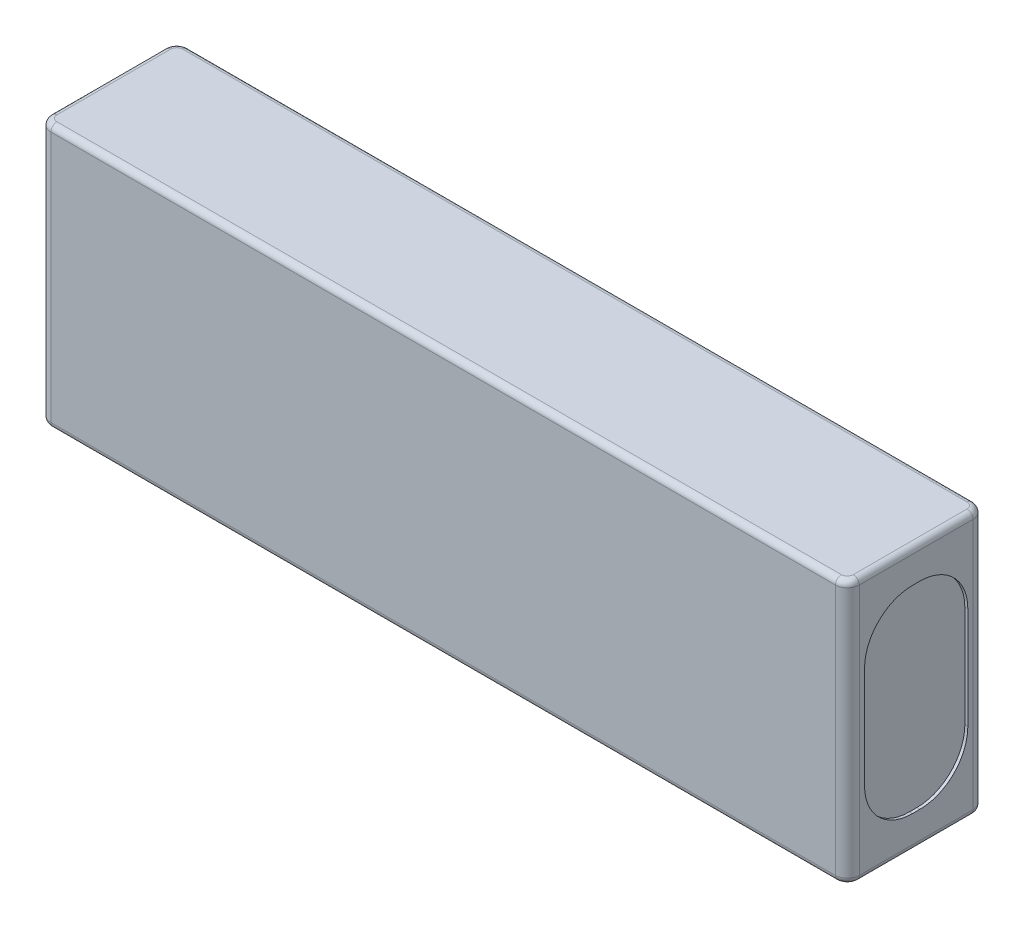
from build123d import *

# Parameters (mm, degrees)
SKETCH1_W           = 135
SKETCH1_H           = 44
BOSS_EXTRUDE1_DEPTH = 23
CUT_EXTRUDE1_DEPTH  = 0.5
CUT_EXTRUDE2_DEPTH  = 0.5
FILLET1_R           = 2
FILLET2_R           = 1


with BuildPart() as part:
    # Sketch1 → Boss-Extrude1 (new body)
    with BuildSketch(Plane(origin=(0, 0, -15), x_dir=(-1, 0, 0), z_dir=(0, 0, -1))):
        with Locations((-1.5, 0)):
            Rectangle(SKETCH1_W, SKETCH1_H)
    extrude(amount=-BOSS_EXTRUDE1_DEPTH)

    # Sketch2 → Cut-Extrude1 (cut)
    with BuildSketch(Plane(origin=(69, 0, 0), x_dir=(0, 0, -1), z_dir=(1, 0, 0))):
        with BuildLine():
            Line((-5.125, 8.5), (-5.125, -8.5))
            ThreePointArc((-5.125, -8.5), (-2.781854249, -14.156854249), (2.875, -16.5))
            Line((2.875, -16.5), (4.125, -16.5))
            ThreePointArc((4.125, -16.5), (9.781854249, -14.156854249), (12.125, -8.5))
            Line((12.125, -8.5), (12.125, 8.5))
            ThreePointArc((12.125, 8.5), (9.781854249, 14.156854249), (4.125, 16.5))
            Line((4.125, 16.5), (2.875, 16.5))
            ThreePointArc((2.875, 16.5), (-2.781854249, 14.156854249), (-5.125, 8.5))
        make_face()
    extrude(amount=-CUT_EXTRUDE1_DEPTH, mode=Mode.SUBTRACT)

    # Sketch3 → Cut-Extrude2 (cut)
    with BuildSketch(Plane.ZY.offset(66)):
        with BuildLine():
            Line((-2.875, 16.5), (-4.125, 16.5))
            ThreePointArc((-4.125, 16.5), (-9.781854249, 14.156854249), (-12.125, 8.5))
            Line((-12.125, 8.5), (-12.125, -8.5))
            ThreePointArc((-12.125, -8.5), (-9.781854249, -14.156854249), (-4.125, -16.5))
            Line((-4.125, -16.5), (-2.875, -16.5))
            ThreePointArc((-2.875, -16.5), (2.781854249, -14.156854249), (5.125, -8.5))
            Line((5.125, -8.5), (5.125, 8.5))
            ThreePointArc((5.125, 8.5), (2.781854249, 14.156854249), (-2.875, 16.5))
        make_face()
    extrude(amount=-CUT_EXTRUDE2_DEPTH, mode=Mode.SUBTRACT)

    # Fillet1
    fillet1_edges = [part.edges().sort_by_distance(p)[0] for p in [
        (-66, 0, 8),
        (69, 0, 8),
        (-66, 0, -15),
        (69, 0, -15),
    ]]
    fillet(fillet1_edges, radius=FILLET1_R)

    # Fillet2
    fillet2_edges = [part.edges().sort_by_distance(p)[0] for p in [
        (1.5, -22, -15),
        (1.5, 22, -15),
        (-66, 22, -3.5),
        (1.5, 22, 8),
        (69, 22, -3.5),
        (68.414213562, 22, 7.414213562),
        (68.414213562, 22, -14.414213562),
        (-65.414213562, 22, 7.414213562),
        (-65.414213562, 22, -14.414213562),
        (-66, -22, -3.5),
        (69, -22, -3.5),
        (1.5, -22, 8),
        (68.414213562, -22, 7.414213562),
        (68.414213562, -22, -14.414213562),
        (-65.414213562, -22, 7.414213562),
        (-65.414213562, -22, -14.414213562),
    ]]
    fillet(fillet2_edges, radius=FILLET2_R)


solid = part.part
